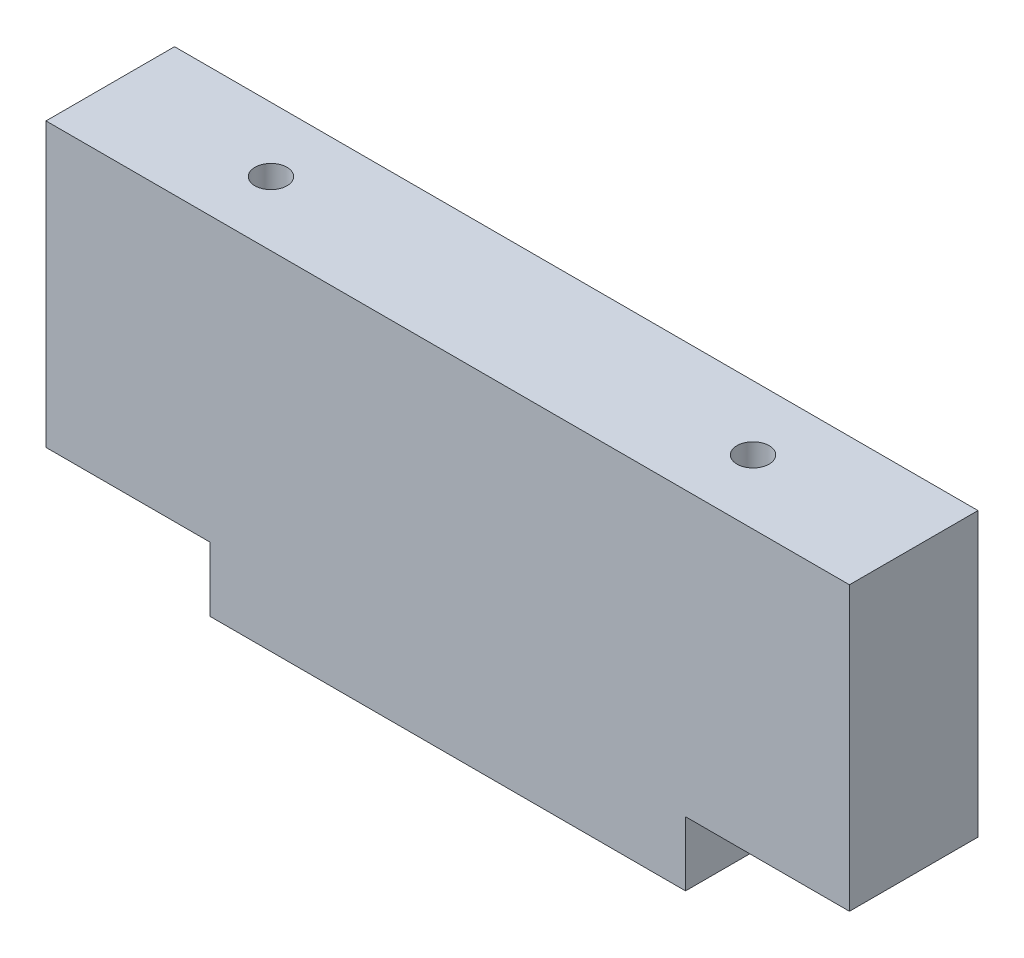
from build123d import *

# Parameters (mm, degrees)
BOSS_EXTRUDE1_DEPTH   = 10
M6_TAPPED_HOLE1_D     = 5
M6_TAPPED_HOLE1_DEPTH = 15
M6_TAPPED_HOLE1_TIP   = 1.502151548
M6_TAPPED_HOLE2_D     = 5
M6_TAPPED_HOLE2_DEPTH = 15
M6_TAPPED_HOLE2_TIP   = 1.502151548


with BuildPart() as part:
    # Sketch1 → Boss-Extrude1 (new body, symmetric)
    with BuildSketch(Plane.XY):
        Polygon((-37, 0), (37, 0), (37, 10), (62.5, 10), (62.5, 54), (-62.5, 54), (-62.5, 10), (-37, 10), align=None)
    extrude(amount=BOSS_EXTRUDE1_DEPTH, both=True)

    # M6 Tapped Hole1
    with Locations(Plane(origin=(0, 10, 0), x_dir=(-1, 0, 0), z_dir=(0, -1, 0))):
        with Locations((50, 0), (-50, 0)):
            Hole(M6_TAPPED_HOLE1_D / 2, depth=M6_TAPPED_HOLE1_DEPTH)
            with Locations((0, 0, -(M6_TAPPED_HOLE1_DEPTH + M6_TAPPED_HOLE1_TIP / 2))):  # 118° drill point
                Cone(0, M6_TAPPED_HOLE1_D / 2, M6_TAPPED_HOLE1_TIP, mode=Mode.SUBTRACT)

    # M6 Tapped Hole2
    with Locations(Plane(origin=(0, 54, 0), x_dir=(1, 0, 0), z_dir=(0, 1, 0))):
        with Locations((-37.5, 0), (37.5, 0)):
            Hole(M6_TAPPED_HOLE2_D / 2, depth=M6_TAPPED_HOLE2_DEPTH)
            with Locations((0, 0, -(M6_TAPPED_HOLE2_DEPTH + M6_TAPPED_HOLE2_TIP / 2))):  # 118° drill point
                Cone(0, M6_TAPPED_HOLE2_D / 2, M6_TAPPED_HOLE2_TIP, mode=Mode.SUBTRACT)


solid = part.part
